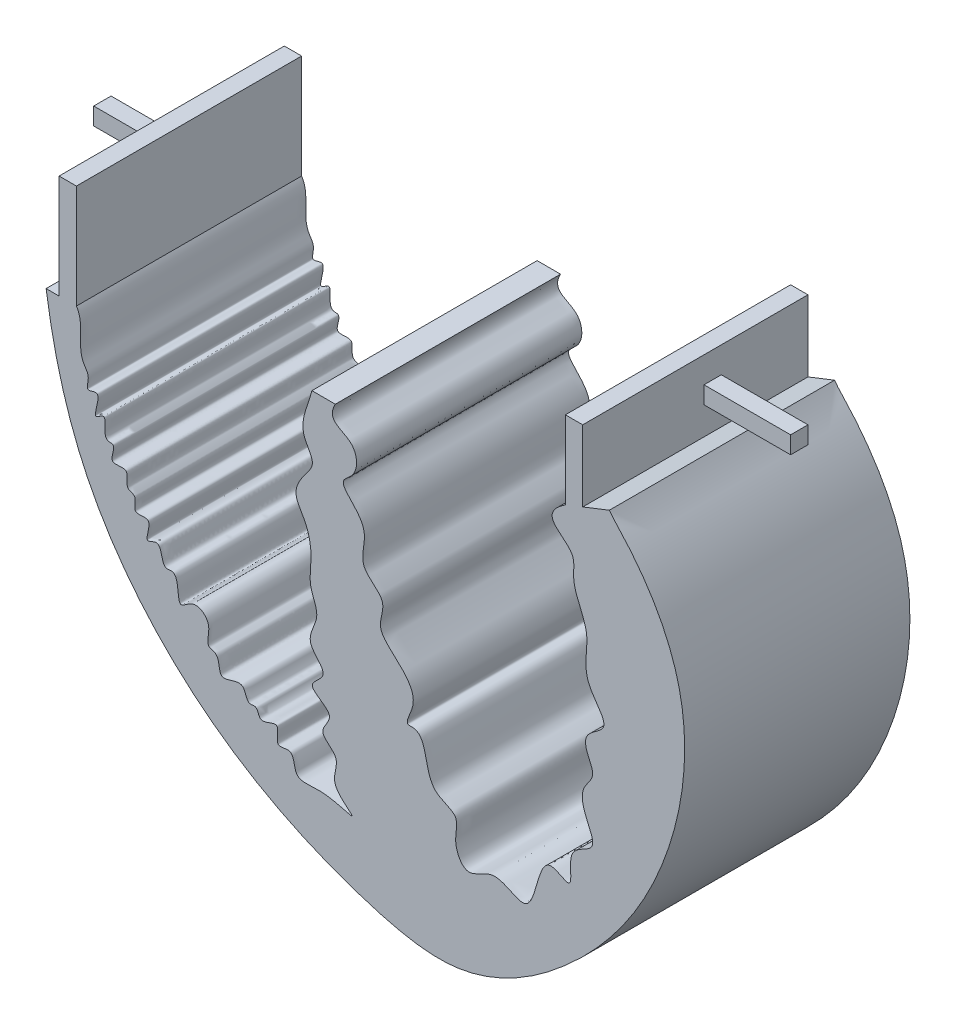
from build123d import *

# Parameters (mm, degrees)
BOSS_EXTRUDE1_DEPTH = 33.02
SKETCH2_W           = 2.54
SKETCH2_H           = 2.54
BOSS_EXTRUDE2_DEPTH = 12.7
SKETCH3_W           = 2.54
SKETCH3_H           = 2.54
BOSS_EXTRUDE3_DEPTH = 12.7


with BuildPart() as part:
    # Sketch1 → Boss-Extrude1 (new body)
    with BuildSketch(Plane.XY):
        with BuildLine():
            Line((156.106031245, 303.390768235), (158.008998456, 303.390768235))
            Line((158.008998456, 303.390768235), (158.008998456, 318.630768235))
            Line((158.008998456, 318.630768235), (160.548998456, 318.630768235))
            Line((160.548998456, 318.630768235), (160.548998456, 303.390768235))
            add(Edge.make_bspline(
                [(160.548998456, 303.390768235), (161.840810476, 301.443359262), (160.250956027, 297.852651647), (162.639094308, 295.41662597), (161.72166044, 293.107234673), (164.781447283, 294.770350028), (162.39566906, 289.672175782), (165.440628546, 292.455907008), (164.098899161, 288.334327444), (166.60954156, 288.720531871), (164.784154189, 285.500296623), (168.730425511, 286.920292116), (167.462604122, 283.885452186), (169.659247633, 283.679892549), (168.410554871, 280.905625742), (172.244386765, 282.34189187), (170.061532194, 277.96804836), (173.286445956, 280.170419596), (172.836773922, 276.285298176), (175.857943126, 277.232320913), (174.95140551, 271.618941917), (177.836072038, 274.969534175), (180.810316221, 272.789240188), (179.247342413, 269.770675033), (181.711627392, 269.544042864), (181.006977008, 265.579223865), (185.332167561, 268.688919922), (185.426454035, 265.276816452), (187.128838306, 265.900865218), (187.295300145, 263.459479363), (190.876494595, 266.155571451), (189.335066676, 261.728140721), (192.501254768, 263.176689779), (192.340760215, 258.853353992), (196.496161596, 260.400513394), (203.091149438, 257.78642672), (197.119021393, 261.507154485), (199.787020442, 265.257412985), (195.451730113, 267.162293282), (199.259869794, 270.408009393), (193.387434177, 272.181884509), (198.199721975, 274.826809254), (193.413130964, 277.72158183), (196.694345124, 281.471938069), (194.506833195, 284.844918277), (195.155469766, 288.693248217), (194.64086131, 292.398623496), (192.086983348, 295.63875969), (193.698148383, 298.433730213), (195.831067961, 300.855456636), (192.543315861, 304.493556232), (194.642747282, 307.906103466), (195.074450088, 309.912787822)],
                knots=[0, 0, 0, 0, 0.051919163, 0.064007685, 0.07549919, 0.084668612, 0.10720964, 0.115505732, 0.136945225, 0.142203582, 0.158114896, 0.172985636, 0.189193273, 0.196237379, 0.210675295, 0.224359556, 0.24371626, 0.253596324, 0.275436832, 0.281725288, 0.310341395, 0.324821364, 0.346332471, 0.366830331, 0.372892646, 0.392675225, 0.415786432, 0.430902, 0.436666418, 0.446704146, 0.464888533, 0.482308364, 0.494361239, 0.512123108, 0.542429613, 0.575247796, 0.602910139, 0.629687608, 0.651763269, 0.671433761, 0.699314974, 0.718217324, 0.745268963, 0.776013839, 0.801534389, 0.826228514, 0.862325635, 0.884844537, 0.910317817, 0.927809266, 0.949760712, 1, 1, 1, 1], degree=3))
            Line((195.074450088, 309.912787822), (198.510595777, 309.912787822))
            add(Edge.make_bspline(
                [(198.510595777, 309.912787822), (197.023380523, 307.185551245), (201.745388275, 307.362657877), (201.907046694, 302.344488404), (198.939635821, 300.69879161), (201.46326596, 298.263143369), (203.485875999, 295.641372698), (201.505991196, 290.940771209), (206.520878741, 288.811924176), (204.403608675, 284.840579621), (207.259496886, 282.187310117), (209.822955085, 279.849652934), (210.140849663, 277.093565791), (208.589492444, 274.449085401), (212.314402754, 274.83007287), (210.893647391, 267.774037068), (217.050850088, 266.87759465), (215.577318934, 263.123148611), (217.868120504, 258.950344703), (221.808619746, 263.162915754), (226.975453852, 258.494830156), (227.949947188, 264.066759542), (229.667333922, 268.112175429), (234.002977415, 264.668151287), (231.852678163, 271.18036597), (237.292331838, 271.926073936), (235.050111862, 275.974086684), (234.246376724, 279.169245618), (236.960962034, 281.718332174), (235.252441085, 283.954509521), (235.027987848, 286.833031251), (239.640418941, 288.496705906), (234.068850409, 293.382823199), (236.523101877, 299.438760497), (232.946305114, 303.982238357), (234.136214336, 309.889104917), (227.671804132, 310.911582782), (232.242900174, 314.000966379)],
                knots=[0, 0, 0, 0, 0.040477106, 0.069912843, 0.084299036, 0.102582179, 0.130291202, 0.162598486, 0.194400956, 0.219561012, 0.241542037, 0.27557684, 0.294733334, 0.311598964, 0.314496036, 0.371030933, 0.396647255, 0.421678843, 0.446128969, 0.477508818, 0.513278333, 0.551089671, 0.573166895, 0.593986151, 0.625076682, 0.653560869, 0.678391875, 0.707285435, 0.726541618, 0.748878759, 0.761709061, 0.787967935, 0.825022061, 0.874318518, 0.92384303, 0.943136919, 1, 1, 1, 1], degree=3))
            Line((232.242900174, 314.000966379), (232.242900174, 325.430966379))
            Line((232.242900174, 325.430966379), (234.782900174, 325.430966379))
            Line((234.782900174, 325.430966379), (234.782900174, 315.001155653))
            Line((234.782900174, 315.001155653), (238.685163096, 316.537770424))
            add(Edge.make_bspline(
                [(156.106031245, 303.390768235), (157.104104191, 296.550361607), (161.019969178, 280.5969625), (177.796499222, 260.091211673), (198.125508089, 249.891252021), (218.238222954, 245.29607375), (234.550765535, 255.901833712), (247.937650513, 274.044596413), (252.142183865, 297.702907226), (243.608906344, 311.342567704), (239.060814084, 315.979524006), (238.685163096, 316.537770424)],
                knots=[0.120046572, 0.120046572, 0.120046572, 0.120046572, 0.184833858, 0.273021776, 0.359649237, 0.397816634, 0.461195161, 0.526426676, 0.612455038, 0.666069007, 0.672633998, 0.672633998, 0.672633998, 0.672633998], degree=3))
        make_face()
    extrude(amount=BOSS_EXTRUDE1_DEPTH)

    # Sketch2 → Boss-Extrude2 (add)
    with BuildSketch(Plane.ZY.offset(-158.008998456)):
        with Locations((13.97, 311.010768235)):
            Rectangle(SKETCH2_W, SKETCH2_H)
    extrude(amount=BOSS_EXTRUDE2_DEPTH)

    # Sketch3 → Boss-Extrude3 (add)
    with BuildSketch(Plane(origin=(234.782900174, 0, 0), x_dir=(0, 0, -1), z_dir=(1, 0, 0))):
        with Locations((-13.97, 320.350966379)):
            Rectangle(SKETCH3_W, SKETCH3_H)
    extrude(amount=BOSS_EXTRUDE3_DEPTH)


solid = part.part
